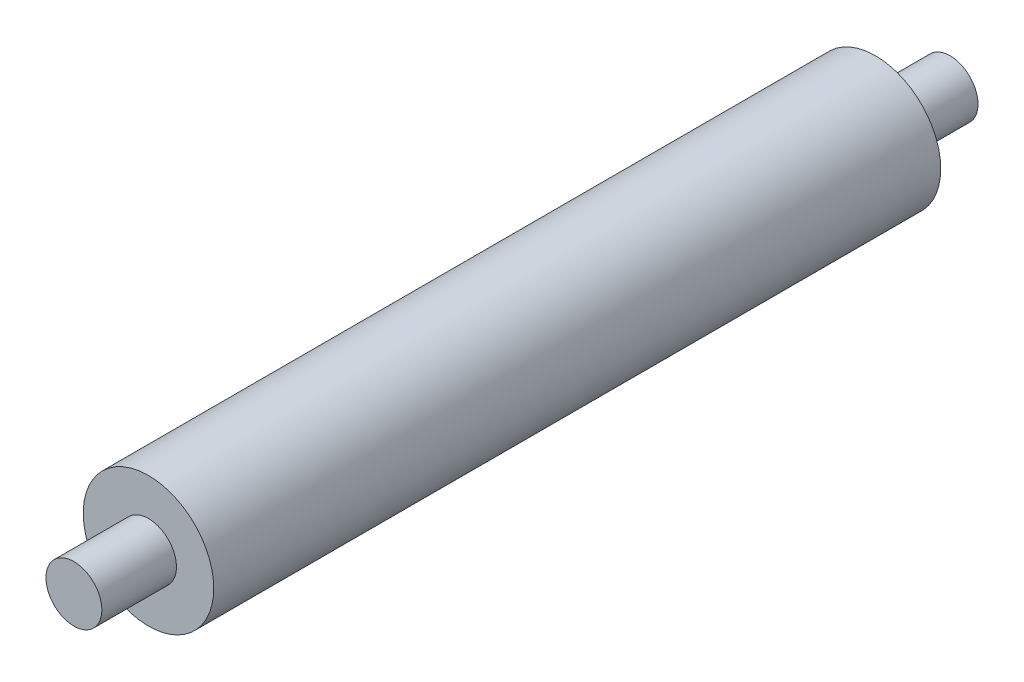
from build123d import *

# Parameters (mm, degrees)
SKETCH_1_R           = 3.5
EXTRUDE_1_DEPTH      = 39
SKETCH_2_R           = 1.5
EXTRUDE_3_DEPTH      = 4
EXTRUDE_3_DEPTH_BACK = 43


with BuildPart() as part:
    # 草图1 → 凸台-拉伸1 (new body)
    with BuildSketch(Plane.XY):
        Circle(SKETCH_1_R)
    extrude(amount=EXTRUDE_1_DEPTH)

    # 草图2 → 凸台-拉伸3 (add, two sides)
    with BuildSketch(Plane.XY.offset(39)) as extrude_3_sk:
        Circle(SKETCH_2_R)
    extrude(amount=EXTRUDE_3_DEPTH)
    extrude(extrude_3_sk.sketch, amount=-EXTRUDE_3_DEPTH_BACK)


solid = part.part
